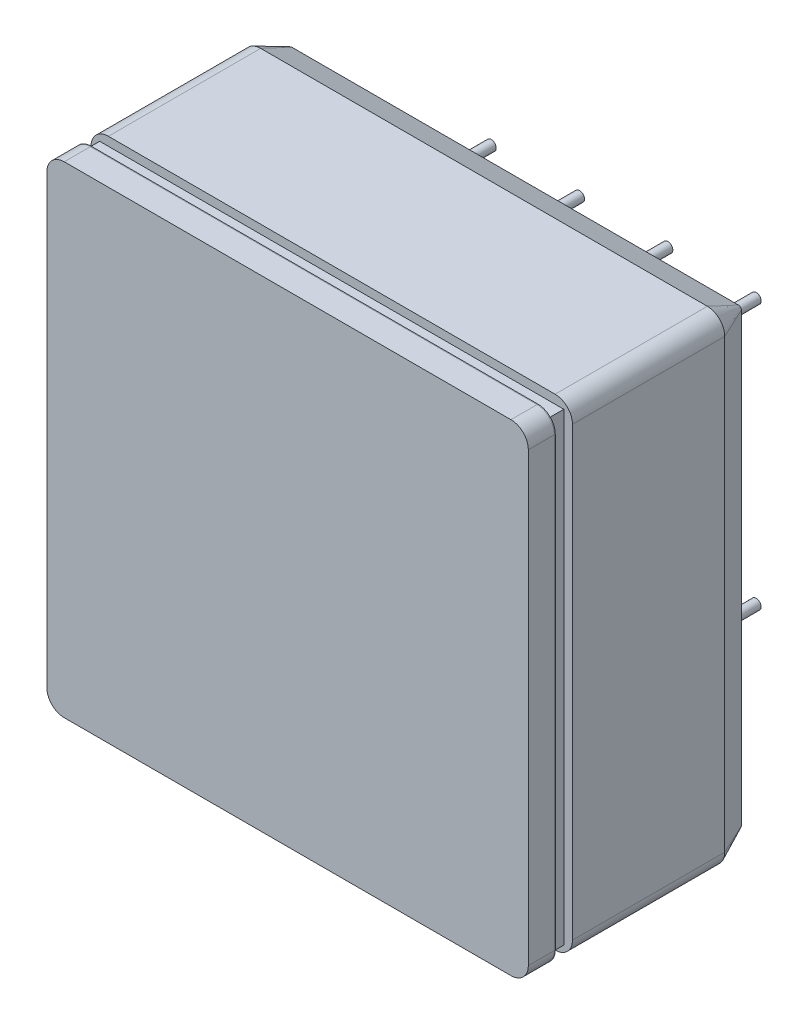
from build123d import *

# Parameters (mm, degrees)
METAL_CASE_AT_HV_DEPTH = 8.76
SKETCH3_W              = 24.737677246
SKETCH3_H              = 24.830501551
PHOTOCATHODE_DEPTH     = 0.1
SKETCH5_W              = 26.7
SKETCH5_H              = 26.7
SKETCH5_W_2            = 23.2
SKETCH5_H_2            = 23.2
BOSS_EXTRUDE3_DEPTH    = 0.99
SKETCH6_W              = 23.2
SKETCH6_H              = 23.2
MIRRORED_SURFACE_DEPTH = 0.05
FRONT_GLASS_DEPTH      = 1.5
SKETCH8_R              = 0.285
PINS_DEPTH             = 5.5
SKETCH9_W              = 1.403236588
SKETCH9_H              = 1.496318302
SKETCH9_W_2            = 1.502916358
SKETCH9_H_2            = 1.880163391
SKETCH9_W_3            = 1.432017479
SKETCH9_W_4            = 4.227959696
SKETCH9_W_5            = 1.836353851
SKETCH9_H_3            = 11.695124286
SKETCH9_H_4            = 4.871079897
SKETCH9_W_6            = 1.828629866
SKETCH9_H_5            = 1.71959621
SKETCH9_W_7            = 1.615933227
SKETCH9_W_8            = 1.365330314
SKETCH9_W_9            = 1.525378005
SKETCH9_H_6            = 1.496732956
SKETCH9_W_10           = 17.055037943
SKETCH9_H_7            = 1.444241572
SKETCH9_H_8            = 1.617700465
SKETCH9_H_9            = 1.513765196
SKETCH9_H_10           = 14.892572142
SKETCH9_H_11           = 1.645870576
SKETCH9_H_12           = 1.829290868
SKETCH9_W_11           = 1.140707165
SKETCH9_H_13           = 1.492116291
SKETCH9_W_12           = 1.724036428
SKETCH9_W_13           = 1.316199483
SKETCH9_H_14           = 1.570615298
SKETCH9_W_14           = 1.593474923
SKETCH9_W_15           = 1.889006141
SKETCH9_H_15           = 2.206356806
SKETCH9_W_16           = 6.877190486
SKETCH9_H_16           = 1.783898062
SKETCH9_W_17           = 1.759836844
SKETCH9_H_17           = 1.481039903
CUT_EXTRUDE1_DEPTH     = 5.5
RUBBER_DEPTH           = 1.79
RUBBER_TAPER           = 25


with BuildPart() as part:
    # Sketch2 → metal-case-at-HV (new body)
    with BuildSketch(Plane.XY.offset(-2.54)):
        with BuildLine():
            Line((1, 27.7), (26.7, 27.7))
            ThreePointArc((26.7, 27.7), (27.407106781, 27.407106781), (27.7, 26.7))
            Line((27.7, 26.7), (27.7, 1))
            ThreePointArc((27.7, 1), (27.407106781, 0.292893219), (26.7, 0))
            Line((26.7, 0), (1, 0))
            ThreePointArc((1, 0), (0.292893219, 0.292893219), (0, 1))
            Line((0, 1), (0, 26.7))
            ThreePointArc((0, 26.7), (0.292893219, 27.407106781), (1, 27.7))
        make_face()
    extrude(amount=-METAL_CASE_AT_HV_DEPTH)

    # Sketch3 → photocathode (add)
    with BuildSketch(Plane.XY.offset(-2.54)):
        with Locations((13.757175695, 13.780381772)):
            Rectangle(SKETCH3_W, SKETCH3_H)
    extrude(amount=PHOTOCATHODE_DEPTH)

    # Sketch5 → Boss-Extrude3 (add)
    with BuildSketch(Plane.XY.offset(-2.54)):
        with Locations((13.85, 13.85)):
            Rectangle(SKETCH5_W, SKETCH5_H)
        with Locations((13.85, 13.85)):
            Rectangle(SKETCH5_W_2, SKETCH5_H_2, mode=Mode.SUBTRACT)
    extrude(amount=BOSS_EXTRUDE3_DEPTH)

    # Sketch6 → mirrored-surface (add)
    with BuildSketch(Plane.XY.offset(-1.55)):
        with BuildLine():
            Line((1, 27.7), (26.7, 27.7))
            ThreePointArc((26.7, 27.7), (27.407106781, 27.407106781), (27.7, 26.7))
            Line((27.7, 26.7), (27.7, 1))
            ThreePointArc((27.7, 1), (27.407106781, 0.292893219), (26.7, 0))
            Line((26.7, 0), (1, 0))
            ThreePointArc((1, 0), (0.292893219, 0.292893219), (0, 1))
            Line((0, 1), (0, 26.7))
            ThreePointArc((0, 26.7), (0.292893219, 27.407106781), (1, 27.7))
        make_face()
        with Locations((13.85, 13.85)):
            Rectangle(SKETCH6_W, SKETCH6_H, mode=Mode.SUBTRACT)
    extrude(amount=MIRRORED_SURFACE_DEPTH)

    # Sketch8 → pins (add)
    with BuildSketch(Plane(origin=(0, 0, -11.3), x_dir=(-1, 0, 0), z_dir=(0, 0, -1))):
        with Locations((-24.01, 3.69)):
            Circle(SKETCH8_R)
        with Locations((-21.47, 3.69)):
            Circle(SKETCH8_R)
        with Locations((-18.93, 3.69)):
            Circle(SKETCH8_R)
        with Locations((-16.39, 3.69)):
            Circle(SKETCH8_R)
        with Locations((-13.85, 3.69)):
            Circle(SKETCH8_R)
        with Locations((-11.31, 3.69)):
            Circle(SKETCH8_R)
        with Locations((-8.77, 3.69)):
            Circle(SKETCH8_R)
        with Locations((-6.23, 3.69)):
            Circle(SKETCH8_R)
        with Locations((-3.69, 3.69)):
            Circle(SKETCH8_R)
        with Locations((-24.01, 6.23)):
            Circle(SKETCH8_R)
        with Locations((-21.47, 6.23)):
            Circle(SKETCH8_R)
        with Locations((-18.93, 6.23)):
            Circle(SKETCH8_R)
        with Locations((-16.39, 6.23)):
            Circle(SKETCH8_R)
        with Locations((-13.85, 6.23)):
            Circle(SKETCH8_R)
        with Locations((-11.31, 6.23)):
            Circle(SKETCH8_R)
        with Locations((-8.77, 6.23)):
            Circle(SKETCH8_R)
        with Locations((-6.23, 6.23)):
            Circle(SKETCH8_R)
        with Locations((-3.69, 6.23)):
            Circle(SKETCH8_R)
        with Locations((-24.01, 8.77)):
            Circle(SKETCH8_R)
        with Locations((-21.47, 8.77)):
            Circle(SKETCH8_R)
        with Locations((-18.93, 8.77)):
            Circle(SKETCH8_R)
        with Locations((-16.39, 8.77)):
            Circle(SKETCH8_R)
        with Locations((-13.85, 8.77)):
            Circle(SKETCH8_R)
        with Locations((-11.31, 8.77)):
            Circle(SKETCH8_R)
        with Locations((-8.77, 8.77)):
            Circle(SKETCH8_R)
        with Locations((-6.23, 8.77)):
            Circle(SKETCH8_R)
        with Locations((-3.69, 8.77)):
            Circle(SKETCH8_R)
        with Locations((-24.01, 11.31)):
            Circle(SKETCH8_R)
        with Locations((-21.47, 11.31)):
            Circle(SKETCH8_R)
        with Locations((-18.93, 11.31)):
            Circle(SKETCH8_R)
        with Locations((-16.39, 11.31)):
            Circle(SKETCH8_R)
        with Locations((-13.85, 11.31)):
            Circle(SKETCH8_R)
        with Locations((-11.31, 11.31)):
            Circle(SKETCH8_R)
        with Locations((-8.77, 11.31)):
            Circle(SKETCH8_R)
        with Locations((-6.23, 11.31)):
            Circle(SKETCH8_R)
        with Locations((-3.69, 11.31)):
            Circle(SKETCH8_R)
        with Locations((-24.01, 13.85)):
            Circle(SKETCH8_R)
        with Locations((-21.47, 13.85)):
            Circle(SKETCH8_R)
        with Locations((-18.93, 13.85)):
            Circle(SKETCH8_R)
        with Locations((-16.39, 13.85)):
            Circle(SKETCH8_R)
        with Locations((-13.85, 13.85)):
            Circle(SKETCH8_R)
        with Locations((-11.31, 13.85)):
            Circle(SKETCH8_R)
        with Locations((-8.77, 13.85)):
            Circle(SKETCH8_R)
        with Locations((-6.23, 13.85)):
            Circle(SKETCH8_R)
        with Locations((-3.69, 13.85)):
            Circle(SKETCH8_R)
        with Locations((-24.01, 16.39)):
            Circle(SKETCH8_R)
        with Locations((-21.47, 16.39)):
            Circle(SKETCH8_R)
        with Locations((-18.93, 16.39)):
            Circle(SKETCH8_R)
        with Locations((-16.39, 16.39)):
            Circle(SKETCH8_R)
        with Locations((-13.85, 16.39)):
            Circle(SKETCH8_R)
        with Locations((-11.31, 16.39)):
            Circle(SKETCH8_R)
        with Locations((-8.77, 16.39)):
            Circle(SKETCH8_R)
        with Locations((-6.23, 16.39)):
            Circle(SKETCH8_R)
        with Locations((-3.69, 16.39)):
            Circle(SKETCH8_R)
        with Locations((-24.01, 18.93)):
            Circle(SKETCH8_R)
        with Locations((-21.47, 18.93)):
            Circle(SKETCH8_R)
        with Locations((-18.93, 18.93)):
            Circle(SKETCH8_R)
        with Locations((-16.39, 18.93)):
            Circle(SKETCH8_R)
        with Locations((-13.85, 18.93)):
            Circle(SKETCH8_R)
        with Locations((-11.31, 18.93)):
            Circle(SKETCH8_R)
        with Locations((-8.77, 18.93)):
            Circle(SKETCH8_R)
        with Locations((-6.23, 18.93)):
            Circle(SKETCH8_R)
        with Locations((-3.69, 18.93)):
            Circle(SKETCH8_R)
        with Locations((-24.01, 21.47)):
            Circle(SKETCH8_R)
        with Locations((-21.47, 21.47)):
            Circle(SKETCH8_R)
        with Locations((-18.93, 21.47)):
            Circle(SKETCH8_R)
        with Locations((-16.39, 21.47)):
            Circle(SKETCH8_R)
        with Locations((-13.85, 21.47)):
            Circle(SKETCH8_R)
        with Locations((-11.31, 21.47)):
            Circle(SKETCH8_R)
        with Locations((-8.77, 21.47)):
            Circle(SKETCH8_R)
        with Locations((-6.23, 21.47)):
            Circle(SKETCH8_R)
        with Locations((-3.69, 21.47)):
            Circle(SKETCH8_R)
        with Locations((-24.01, 24.01)):
            Circle(SKETCH8_R)
        with Locations((-21.47, 24.01)):
            Circle(SKETCH8_R)
        with Locations((-18.93, 24.01)):
            Circle(SKETCH8_R)
        with Locations((-16.39, 24.01)):
            Circle(SKETCH8_R)
        with Locations((-13.85, 24.01)):
            Circle(SKETCH8_R)
        with Locations((-11.31, 24.01)):
            Circle(SKETCH8_R)
        with Locations((-8.77, 24.01)):
            Circle(SKETCH8_R)
        with Locations((-6.23, 24.01)):
            Circle(SKETCH8_R)
        with Locations((-3.69, 24.01)):
            Circle(SKETCH8_R)
    extrude(amount=PINS_DEPTH)

    # Sketch9 → Cut-Extrude1 (cut)
    with BuildSketch(Plane(origin=(0, 0, -16.8), x_dir=(-1, 0, 0), z_dir=(0, 0, -1))):
        with Locations((-21.480019138, 24.113026159)):
            Rectangle(SKETCH9_W, SKETCH9_H)
        with Locations((-16.559216808, 23.921103615)):
            Rectangle(SKETCH9_W_2, SKETCH9_H_2)
        with Locations((-11.149493241, 23.921103615)):
            Rectangle(SKETCH9_W_3, SKETCH9_H_2)
        with Locations((-5.093958278, 24.113026159)):
            Rectangle(SKETCH9_W_4, SKETCH9_H)
        with Locations((-23.96533774, 16.379524364)):
            Rectangle(SKETCH9_W_5, SKETCH9_H_3)
        with Locations((-23.96533774, 5.141508534)):
            Rectangle(SKETCH9_W_5, SKETCH9_H_4)
        with Locations((-18.879223075, 21.590151656)):
            Rectangle(SKETCH9_W_6, SKETCH9_H_5)
        with Locations((-13.758710646, 21.590151656)):
            Rectangle(SKETCH9_W_7, SKETCH9_H_5)
        with Locations((-8.69295177, 21.590151656)):
            Rectangle(SKETCH9_W_8, SKETCH9_H_5)
        with Locations((-3.742667433, 21.478720029)):
            Rectangle(SKETCH9_W_9, SKETCH9_H_6)
        with Locations((-13.896295437, 19.092329501)):
            Rectangle(SKETCH9_W_10, SKETCH9_H_7)
        with Locations((-13.896295437, 13.951861682)):
            Rectangle(SKETCH9_W_10, SKETCH9_H_8)
        with Locations((-13.896295437, 8.881967989)):
            Rectangle(SKETCH9_W_10, SKETCH9_H_9)
        with Locations((-3.742667433, 10.152254656)):
            Rectangle(SKETCH9_W_9, SKETCH9_H_10)
        with Locations((-18.879223075, 16.504452811)):
            Rectangle(SKETCH9_W_6, SKETCH9_H_11)
        with Locations((-13.758710646, 16.504452811)):
            Rectangle(SKETCH9_W_7, SKETCH9_H_11)
        with Locations((-8.69295177, 16.504452811)):
            Rectangle(SKETCH9_W_8, SKETCH9_H_11)
        with Locations((-8.69295177, 11.446607655)):
            Rectangle(SKETCH9_W_8, SKETCH9_H_12)
        with Locations((-8.805263345, 6.274958053)):
            Rectangle(SKETCH9_W_11, SKETCH9_H_13)
        with Locations((-14.11249599, 6.274958053)):
            Rectangle(SKETCH9_W_12, SKETCH9_H_13)
        with Locations((-13.908577517, 11.31726987)):
            Rectangle(SKETCH9_W_13, SKETCH9_H_14)
        with Locations((-18.996800547, 11.446607655)):
            Rectangle(SKETCH9_W_14, SKETCH9_H_12)
        with Locations((-18.879223075, 6.274958053)):
            Rectangle(SKETCH9_W_6, SKETCH9_H_13)
        with Locations((-21.479311338, 3.809146988)):
            Rectangle(SKETCH9_W_15, SKETCH9_H_15)
        with Locations((-13.872079744, 3.597917616)):
            Rectangle(SKETCH9_W_16, SKETCH9_H_16)
        with Locations((-6.657233785, 3.749346696)):
            Rectangle(SKETCH9_W_17, SKETCH9_H_17)
    extrude(amount=-CUT_EXTRUDE1_DEPTH, mode=Mode.SUBTRACT)


with BuildPart() as body_2:
    # Sketch7 → front-glass (new body)
    with BuildSketch(Plane.XY.offset(-1.5)):
        with BuildLine():
            Line((1, 27.7), (26.7, 27.7))
            ThreePointArc((26.7, 27.7), (27.407106781, 27.407106781), (27.7, 26.7))
            Line((27.7, 26.7), (27.7, 1))
            ThreePointArc((27.7, 1), (27.407106781, 0.292893219), (26.7, 0))
            Line((26.7, 0), (1, 0))
            ThreePointArc((1, 0), (0.292893219, 0.292893219), (0, 1))
            Line((0, 1), (0, 26.7))
            ThreePointArc((0, 26.7), (0.292893219, 27.407106781), (1, 27.7))
        make_face()
    extrude(amount=FRONT_GLASS_DEPTH)


with BuildPart() as body_3:
    # Sketch10 → rubber (new body)
    with BuildSketch(Plane(origin=(0, 0, -11.3), x_dir=(-1, 0, 0), z_dir=(0, 0, -1))):
        with BuildLine():
            ThreePointArc((-26.7, 27.7), (-27.407106781, 27.407106781), (-27.7, 26.7))
            Line((-27.7, 26.7), (-27.7, 1))
            ThreePointArc((-27.7, 1), (-27.407106781, 0.292893219), (-26.7, 0))
            Line((-26.7, 0), (-1, 0))
            ThreePointArc((-1, 0), (-0.292893219, 0.292893219), (0, 1))
            Line((0, 1), (0, 26.7))
            ThreePointArc((0, 26.7), (-0.292893219, 27.407106781), (-1, 27.7))
            Line((-1, 27.7), (-26.7, 27.7))
        make_face()
    extrude(amount=RUBBER_DEPTH, taper=RUBBER_TAPER)


solid = Compound([part.part, body_2.part, body_3.part])
